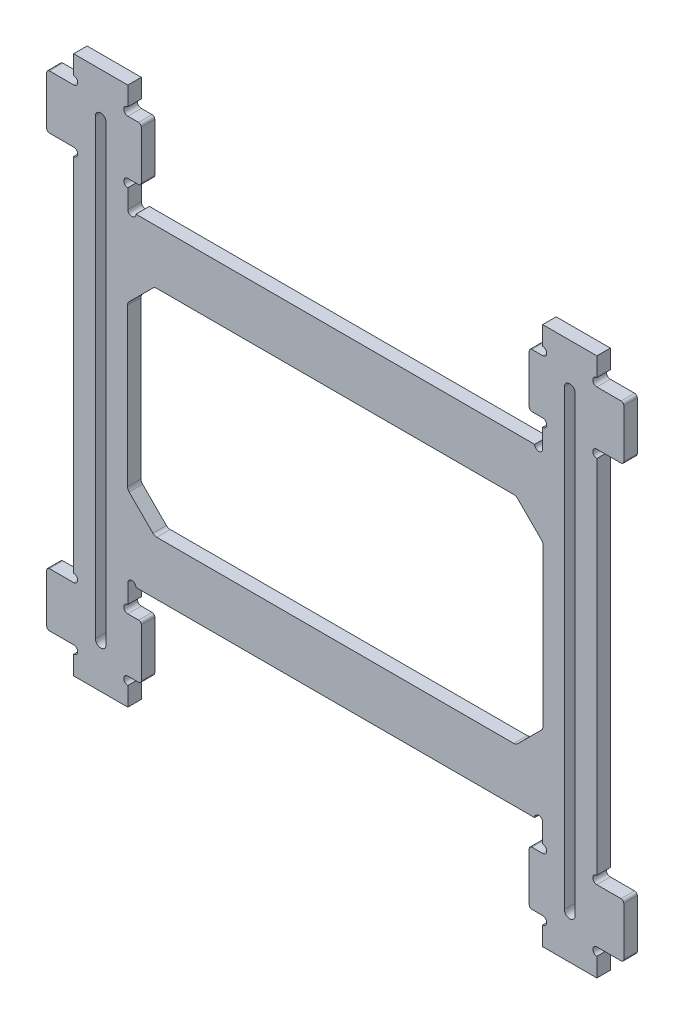
from build123d import *

# Parameters (mm, degrees)
SKETCH_1_W          = 97.1
SKETCH_1_H          = 100
EXTRUDE_1_DEPTH     = 1.25
SKETCH_2_W          = 10
SKETCH_2_H          = 10
EXTRUDE_2_DEPTH     = 2.5
CUT_EXTRUDE_2_DEPTH = 3.5
SKETCH_3_R          = 0.75
CUT_EXTRUDE_1_DEPTH = 3.5
FILLET_1_R          = 0.5
SKETCH_6_W          = 77.1
SKETCH_6_H          = 40
CUT_EXTRUDE_3_DEPTH = 3.5
CHAMFER_1_SIZE      = 5
FILLET_2_R          = 1
CUT_EXTRUDE_4_DEPTH = 3.5


with BuildPart() as part:
    # 草图1 → 凸台-拉伸1 (new body, symmetric)
    with BuildSketch(Plane.XY):
        Rectangle(SKETCH_1_W, SKETCH_1_H)
    extrude(amount=EXTRUDE_1_DEPTH, both=True)

    # 草图2 → 凸台-拉伸2 (add)
    with BuildSketch(Plane.XY.offset(1.25)):
        with Locations((-48.55, -40)):
            Rectangle(SKETCH_2_W, SKETCH_2_H)
        with Locations((-48.55, 40)):
            Rectangle(SKETCH_2_W, SKETCH_2_H)
        with Locations((48.55, -40)):
            Rectangle(SKETCH_2_W, SKETCH_2_H)
        with Locations((48.55, 40)):
            Rectangle(SKETCH_2_W, SKETCH_2_H)
    extrude(amount=-EXTRUDE_2_DEPTH)

    # 草图5 → 切除-拉伸2 (cut, through all)
    with BuildSketch(Plane.XY.offset(1.25)):
        Polygon((-38.5, 50), (-38.5, 45), (-36, 45), (-36, 35), (-38.5, 35), (-38.5, 30), (38.5, 30), (38.5, 35), (36, 35), (36, 45), (38.5, 45), (38.5, 50), align=None)
        Polygon((-38.5, -50), (-38.5, -45), (-36, -45), (-36, -35), (-38.5, -35), (-38.5, -30), (38.5, -30), (38.5, -35), (36, -35), (36, -45), (38.5, -45), (38.5, -50), align=None)
    extrude(amount=-CUT_EXTRUDE_2_DEPTH, mode=Mode.SUBTRACT)

    # 草图3 → 切除-拉伸1 (cut, through all)
    with BuildSketch(Plane.XY.offset(1.25)):
        with Locations((-48.55, 34.25)):
            Circle(SKETCH_3_R)
        with Locations((-48.55, 45.75)):
            Circle(SKETCH_3_R)
        with Locations((-48.55, -34.25)):
            Circle(SKETCH_3_R)
        with Locations((-48.55, -45.75)):
            Circle(SKETCH_3_R)
        with Locations((48.55, -34.25)):
            Circle(SKETCH_3_R)
        with Locations((48.55, -45.75)):
            Circle(SKETCH_3_R)
        with Locations((48.55, 34.25)):
            Circle(SKETCH_3_R)
        with Locations((48.55, 45.75)):
            Circle(SKETCH_3_R)
        with Locations((-38.5, 45.75)):
            Circle(SKETCH_3_R)
        with Locations((-38.5, 34.25)):
            Circle(SKETCH_3_R)
        with Locations((-37.75, 30)):
            Circle(SKETCH_3_R)
        with Locations((-37.75, -30)):
            Circle(SKETCH_3_R)
        with Locations((-38.5, -34.25)):
            Circle(SKETCH_3_R)
        with Locations((-38.5, -45.75)):
            Circle(SKETCH_3_R)
        with Locations((38.5, -45.75)):
            Circle(SKETCH_3_R)
        with Locations((38.5, -34.25)):
            Circle(SKETCH_3_R)
        with Locations((37.75, -30)):
            Circle(SKETCH_3_R)
        with Locations((37.75, 30)):
            Circle(SKETCH_3_R)
        with Locations((38.5, 34.25)):
            Circle(SKETCH_3_R)
        with Locations((38.5, 45.75)):
            Circle(SKETCH_3_R)
    extrude(amount=-CUT_EXTRUDE_1_DEPTH, mode=Mode.SUBTRACT)

    # 圆角1
    fillet_1_edges = [part.edges().sort_by_distance(p)[0] for p in [
        (36, 45, 0),
        (36, 35, 0),
        (-36, 35, 0),
        (-36, 45, 0),
        (-36, -45, 0),
        (-36, -35, 0),
        (36, -35, 0),
        (36, -45, 0),
        (-53.55, -35, 0),
        (-53.55, -45, 0),
        (-53.55, 45, 0),
        (-53.55, 35, 0),
        (53.55, -45, 0),
        (53.55, -35, 0),
        (53.55, 35, 0),
        (53.55, 45, 0),
    ]]
    fillet(fillet_1_edges, radius=FILLET_1_R)

    # 草图6 → 切除-拉伸3 (cut, through all)
    with BuildSketch(Plane.XY.offset(1.25)):
        Rectangle(SKETCH_6_W, SKETCH_6_H)
    extrude(amount=-CUT_EXTRUDE_3_DEPTH, mode=Mode.SUBTRACT)

    # 倒角1
    chamfer_1_edges = [part.edges().sort_by_distance(p)[0] for p in [
        (-38.55, -20, 0),
        (-38.55, 20, 0),
        (38.55, 20, 0),
        (38.55, -20, 0),
    ]]
    chamfer(chamfer_1_edges, length=CHAMFER_1_SIZE)

    # 圆角2
    fillet_2_edges = [part.edges().sort_by_distance(p)[0] for p in [
        (33.55, -20, 0),
        (-33.55, -20, 0),
        (-38.55, 15, 0),
        (-38.55, -15, 0),
        (38.55, 15, 0),
        (38.55, -15, 0),
        (-33.55, 20, 0),
        (33.55, 20, 0),
    ]]
    fillet(fillet_2_edges, radius=FILLET_2_R)

    # 草图7 → 切除-拉伸4 (cut, through all)
    with BuildSketch(Plane.XY.offset(1.25)):
        with BuildLine():
            Line((-44.525, -42), (-44.525, 42))
            ThreePointArc((-44.525, 42), (-43.525, 43), (-42.525, 42))
            Line((-42.525, 42), (-42.525, -42))
            ThreePointArc((-42.525, -42), (-43.525, -43), (-44.525, -42))
        make_face()
        with BuildLine():
            Line((44.525, -42), (44.525, 42))
            ThreePointArc((44.525, 42), (43.525, 43), (42.525, 42))
            Line((42.525, 42), (42.525, -42))
            ThreePointArc((42.525, -42), (43.525, -43), (44.525, -42))
        make_face()
    extrude(amount=-CUT_EXTRUDE_4_DEPTH, mode=Mode.SUBTRACT)


solid = part.part
